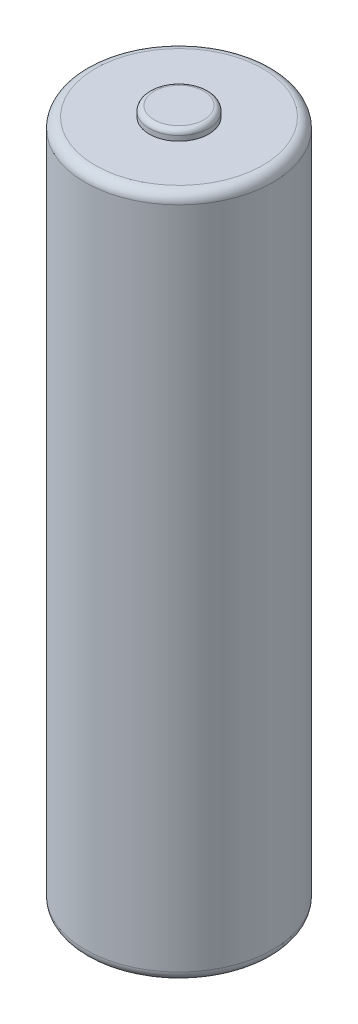
from build123d import *

# Parameters (mm, degrees)
BOSS_EXTRUDE1_DEPTH      = 35
BOSS_EXTRUDE1_DEPTH_BACK = 35
SKETCH1_R                = 9.45
SKETCH2_R                = 9.45
SKETCH2_R_2              = 3
CUT_EXTRUDE1_DEPTH       = 1
FILLET1_R                = 0.5
FILLET2_R                = 1


with BuildPart() as part:
    # Sketch1 → Boss-Extrude1 (new, two sides: drawn at the far end of the back side and taken through both)
    with BuildSketch(Plane(origin=(0, 0, 0), x_dir=(1, 0, 0), z_dir=(0, 1, 0)).offset(-BOSS_EXTRUDE1_DEPTH_BACK)):
        Circle(SKETCH1_R)
    extrude(amount=BOSS_EXTRUDE1_DEPTH + BOSS_EXTRUDE1_DEPTH_BACK)

    # Sketch2 → Cut-Extrude1 (cut)
    with BuildSketch(Plane(origin=(0, 35, 0), x_dir=(1, 0, 0), z_dir=(0, 1, 0))):
        Circle(SKETCH2_R)
        Circle(SKETCH2_R_2, mode=Mode.SUBTRACT)
    extrude(amount=-CUT_EXTRUDE1_DEPTH, mode=Mode.SUBTRACT)

    # Fillet1
    fillet1_edges = [part.edges().sort_by_distance(p)[0] for p in [
        (-3, 35, 0),
    ]]
    fillet(fillet1_edges, radius=FILLET1_R)

    # Fillet2
    fillet2_edges = [part.edges().sort_by_distance(p)[0] for p in [
        (-9.45, -35, 0),
        (-9.45, 34, 0),
    ]]
    fillet(fillet2_edges, radius=FILLET2_R)


solid = part.part
